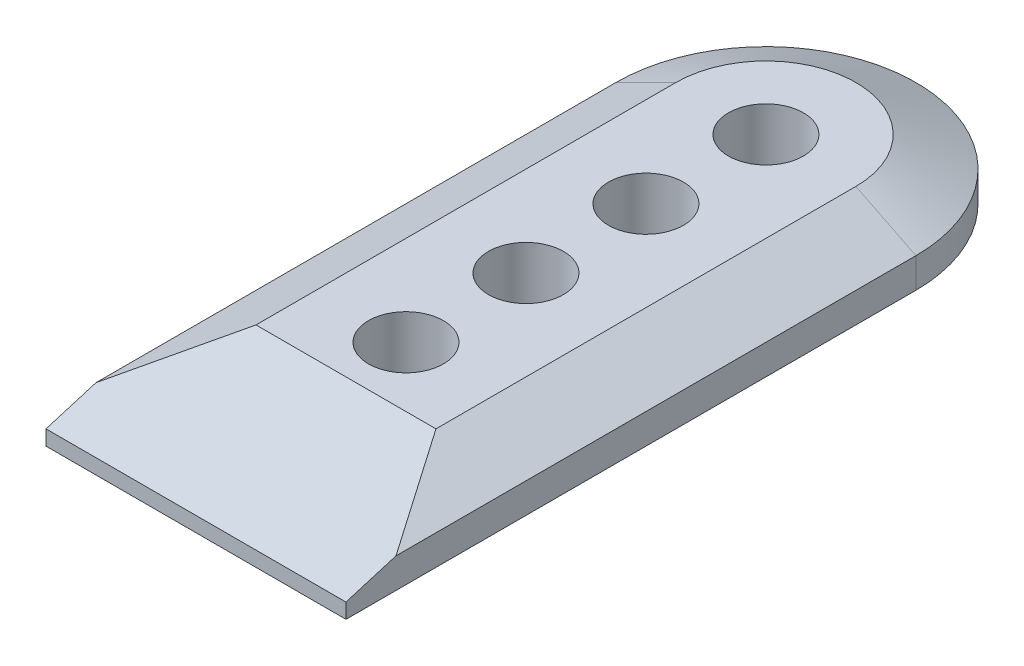
from build123d import *
from OCP.BRepFilletAPI import BRepFilletAPI_MakeChamfer

# Parameters (mm, degrees)
BOSS_EXTRUDE1_DEPTH = 12.7
CHAMFER4_SIZE       = 6.35
CHAMFER4_SIZE2      = 12.7
CHAMFER5_SIZE       = 9.525
CHAMFER5_SIZE2      = 31.75
SKETCH5_R           = 7.9375
CUT_EXTRUDE1_DEPTH  = 157.189348228


with BuildPart() as part:
    # Sketch2 → Boss-Extrude1 (new body)
    with BuildSketch(Plane(origin=(0, 0, 0), x_dir=(1, 0, 0), z_dir=(0, 1, 0))):
        with BuildLine():
            Line((-31.75, 0), (31.75, 0))
            Line((31.75, 0), (31.75, 120.65))
            ThreePointArc((31.75, 120.65), (0, 152.4), (-31.75, 120.65))
            Line((-31.75, 120.65), (-31.75, 0))
        make_face()
    extrude(amount=BOSS_EXTRUDE1_DEPTH)

    # Chamfer4: one chamfer whose edges measure the first distance from different faces: ONE call of the kernel's chamfer builder (chamfer() names one face for all edges)
    chamfer4_edges_1 = [part.edges().sort_by_distance(p)[0] for p in [
        (31.75, 12.7, -60.325),
    ]]
    chamfer4_side_1 = [part.faces().sort_by_distance(p)[0] for p in [
        (31.75, 6.35, -60.325),
    ]]
    chamfer4_edges_2 = [part.edges().sort_by_distance(p)[0] for p in [
        (0, 12.7, -152.4),
    ]]
    chamfer4_side_2 = [part.faces().sort_by_distance(p)[0] for p in [
        (0, 6.35, -152.4),
    ]]
    chamfer4_edges_3 = [part.edges().sort_by_distance(p)[0] for p in [
        (-31.75, 12.7, -60.325),
    ]]
    chamfer4_side_3 = [part.faces().sort_by_distance(p)[0] for p in [
        (-31.75, 6.35, -60.325),
    ]]
    chamfer4 = BRepFilletAPI_MakeChamfer(part.part.solid().wrapped)
    for e in chamfer4_edges_1:
        chamfer4.Add(CHAMFER4_SIZE, CHAMFER4_SIZE2, e.wrapped, chamfer4_side_1[0].wrapped)  # the first distance lies on this face
    for e in chamfer4_edges_2:
        chamfer4.Add(CHAMFER4_SIZE, CHAMFER4_SIZE2, e.wrapped, chamfer4_side_2[0].wrapped)  # the first distance lies on this face
    for e in chamfer4_edges_3:
        chamfer4.Add(CHAMFER4_SIZE, CHAMFER4_SIZE2, e.wrapped, chamfer4_side_3[0].wrapped)  # the first distance lies on this face
    add(Compound.cast(chamfer4.Shape()), mode=Mode.REPLACE)

    # Chamfer5
    chamfer5_edges = [part.edges().sort_by_distance(p)[0] for p in [
        (0, 12.7, 0),
    ]]
    chamfer5_side = [part.faces().sort_by_distance(p)[0] for p in [
        (0, 5.87962963, 0),
    ]]
    chamfer(chamfer5_edges, length=CHAMFER5_SIZE, length2=CHAMFER5_SIZE2, reference=chamfer5_side[0])

    # Sketch5 → Cut-Extrude1 (cut, through all)
    with BuildSketch(Plane(origin=(0, 12.7, 0), x_dir=(1, 0, 0), z_dir=(0, 1, 0))):
        with Locations(Location((0, 120.65, 0), (0, 0, 270))):
            Circle(SKETCH5_R)
        with Locations(Location((0, 95.25, 0), (0, 0, 270))):
            Circle(SKETCH5_R)
        with Locations(Location((0, 69.85, 0), (0, 0, 270))):
            Circle(SKETCH5_R)
        with Locations(Location((0, 44.45, 0), (0, 0, 270))):
            Circle(SKETCH5_R)
    extrude(amount=-CUT_EXTRUDE1_DEPTH, mode=Mode.SUBTRACT)


solid = part.part
